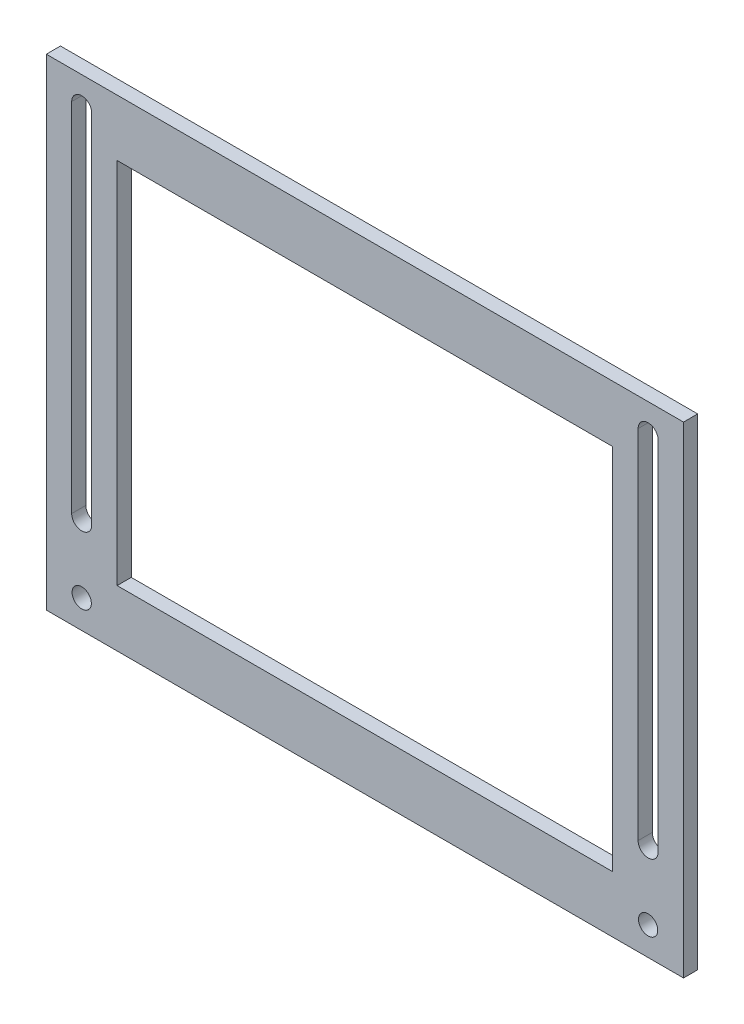
from build123d import *

# Parameters (mm, degrees)
SKETCH1_R           = 2.159
SKETCH1_W           = 111.125
SKETCH1_H           = 82.55
BOSS_EXTRUDE1_DEPTH = 3.175


with BuildPart() as part:
    # Sketch1 → Boss-Extrude1 (new body)
    with BuildSketch(Plane.XY):
        Polygon((0, 0), (15.875, 0), (127, 0), (142.875, 0), (142.875, 107.95), (127, 107.95), (15.875, 107.95), (0, 107.95), align=None)
        with Locations((7.9375, 6.35)):
            Circle(SKETCH1_R, mode=Mode.SUBTRACT)
        with Locations((134.9375, 6.35)):
            Circle(SKETCH1_R, mode=Mode.SUBTRACT)
        with BuildLine():
            Line((10.1854, 101.6), (10.1854, 21.59))
            ThreePointArc((10.1854, 21.59), (7.9375, 19.3421), (5.6896, 21.59))
            Line((5.6896, 21.59), (5.6896, 101.6))
            ThreePointArc((5.6896, 101.6), (7.9375, 103.8479), (10.1854, 101.6))
        make_face(mode=Mode.SUBTRACT)
        with Locations((71.4375, 53.975)):
            Rectangle(SKETCH1_W, SKETCH1_H, mode=Mode.SUBTRACT)
        with BuildLine():
            Line((132.6896, 101.6), (132.6896, 21.59))
            ThreePointArc((132.6896, 21.59), (134.9375, 19.3421), (137.1854, 21.59))
            Line((137.1854, 21.59), (137.1854, 101.6))
            ThreePointArc((137.1854, 101.6), (134.9375, 103.8479), (132.6896, 101.6))
        make_face(mode=Mode.SUBTRACT)
    extrude(amount=BOSS_EXTRUDE1_DEPTH)


solid = part.part
